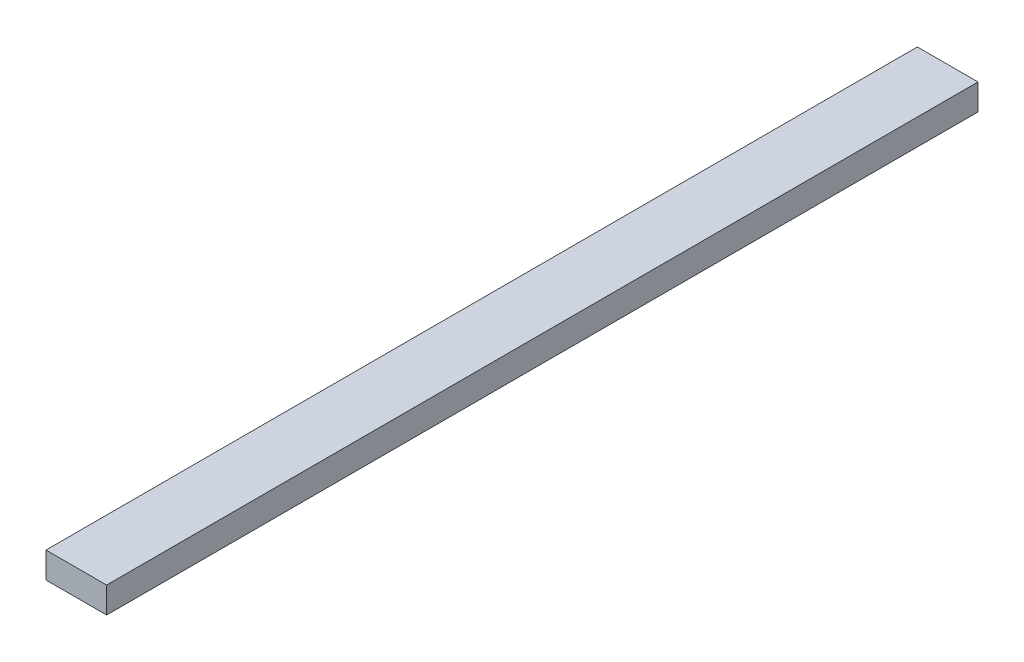
from build123d import *

# Parameters (mm, degrees)
SKETCH1_W           = 88.9
SKETCH1_H           = 38.1
BOSS_EXTRUDE1_DEPTH = 638.899999947


with BuildPart() as part:
    # Sketch1 → Boss-Extrude1 (new body, symmetric)
    with BuildSketch(Plane.XY):
        with Locations((0, -19.05)):
            Rectangle(SKETCH1_W, SKETCH1_H)
    extrude(amount=BOSS_EXTRUDE1_DEPTH, both=True)


solid = part.part
